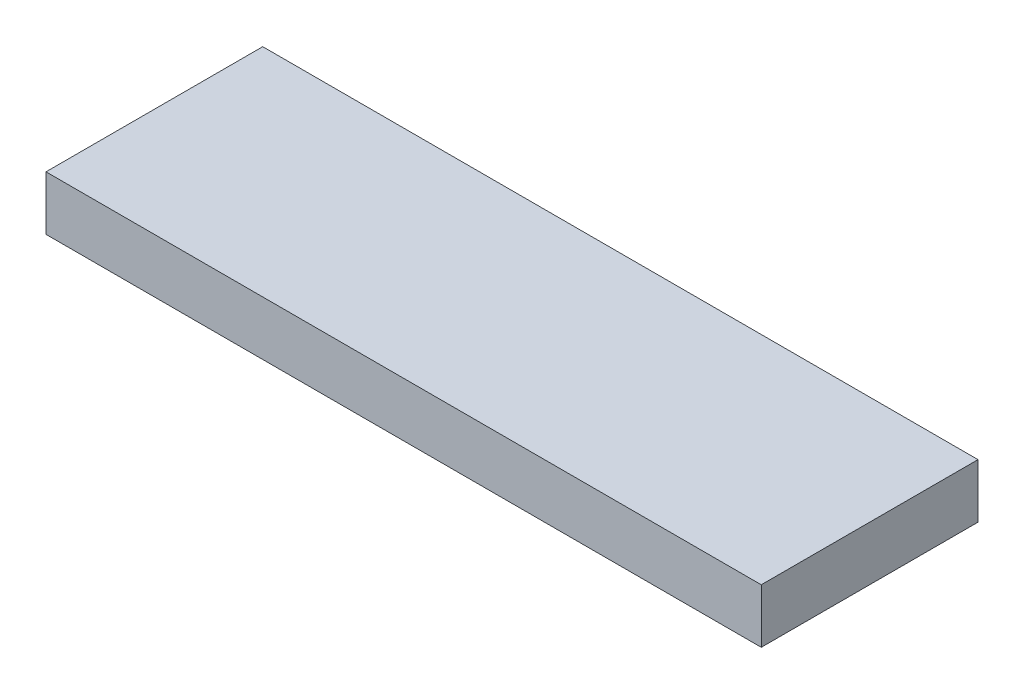
from build123d import *

# Parameters (mm, degrees)
SKETCH1_W           = 41.91
SKETCH1_H           = 12.7
BOSS_EXTRUDE1_DEPTH = 3.175


with BuildPart() as part:
    # Sketch1 → Boss-Extrude1 (new body)
    with BuildSketch(Plane(origin=(0, 0, 0), x_dir=(1, 0, 0), z_dir=(0, 1, 0))):
        Rectangle(SKETCH1_W, SKETCH1_H)
    extrude(amount=BOSS_EXTRUDE1_DEPTH)


solid = part.part
